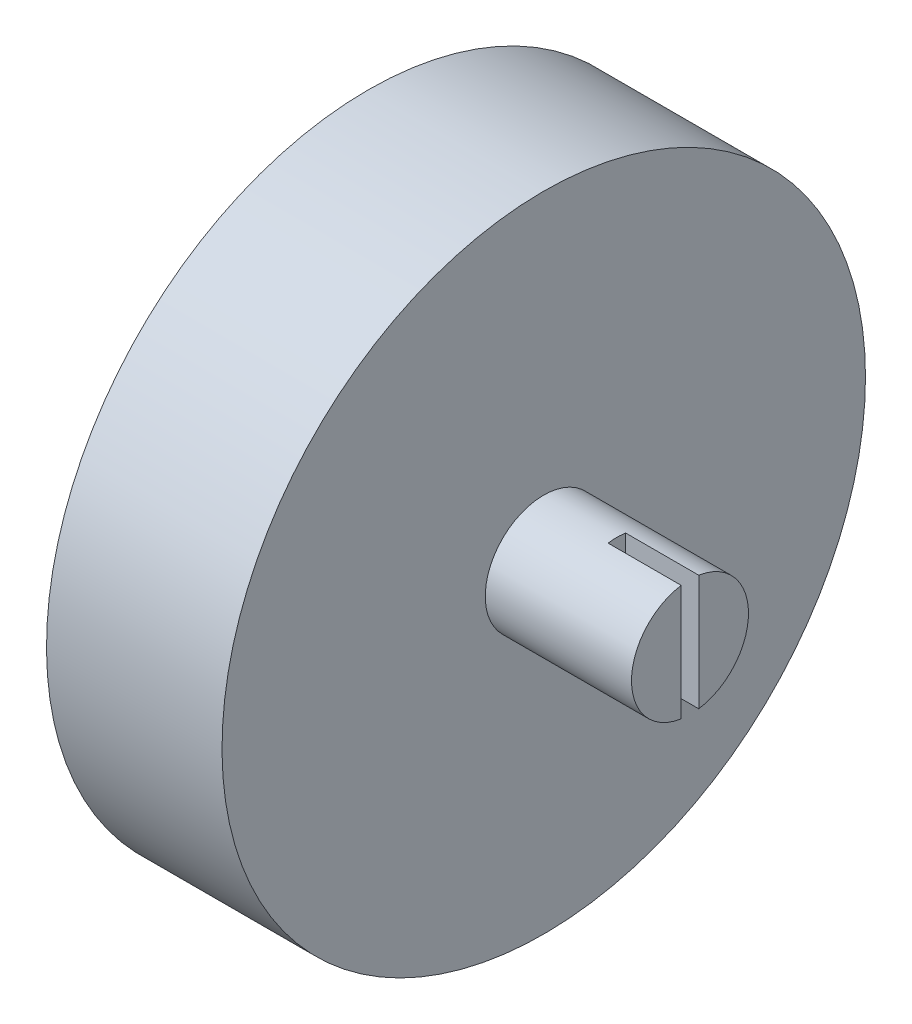
from build123d import *

# Parameters (mm, degrees)
SKETCH1_R           = 22
BOSS_EXTRUDE1_DEPTH = 12
CUT_EXTRUDE2_DEPTH  = 5.5
SKETCH15_W          = 18
SKETCH15_H          = 24.118038922
CUT_EXTRUDE3_DEPTH  = 3
SKETCH16_R          = 4
BOSS_EXTRUDE2_DEPTH = 10
CUT_EXTRUDE4_START  = 22
SKETCH8_W           = 1.2
SKETCH8_H           = 10
CUT_EXTRUDE4_DEPTH  = 5
SKETCH17_W          = 4
SKETCH17_H          = 1.75
BOSS_EXTRUDE3_DEPTH = 1
SKETCH18_W          = 4.25
SKETCH18_H          = 1.737607108
BOSS_EXTRUDE4_DEPTH = 1
SKETCH22_R          = 1.5
CUT_EXTRUDE7_DEPTH  = 7


with BuildPart() as part:
    # Sketch1 → Boss-Extrude1 (new body)
    with BuildSketch(Plane(origin=(0, 0, 0), x_dir=(0, 0, -1), z_dir=(1, 0, 0))):
        Circle(SKETCH1_R)
    extrude(amount=BOSS_EXTRUDE1_DEPTH)

    # Sketch13 → Cut-Extrude2 (cut)
    with BuildSketch(Plane(origin=(0, 0, 0), x_dir=(0, 0, -1), z_dir=(1, 0, 0))):
        with BuildLine():
            Line((-2.670420152, -16.85816067), (-2.670420152, -16.530371213))
            Line((-2.670420152, -16.530371213), (-4.762392892, -10))
            Line((-4.762392892, -10), (-4.762392892, -6.943148259))
            Line((-4.762392892, -6.943148259), (-6.5, -6.943148259))
            Line((-6.5, -6.943148259), (-6.5, 19.556851741))
            Line((-6.5, 19.556851741), (6.5, 19.556851741))
            Line((6.5, 19.556851741), (6.5, -6.943148259))
            Line((6.5, -6.943148259), (4.762392892, -6.943148259))
            Line((4.762392892, -6.943148259), (4.762392892, -10))
            Line((4.762392892, -10), (2.670420152, -16.530371213))
            Line((2.670420152, -16.530371213), (2.670420152, -16.85816067))
            Line((2.670420152, -16.85816067), (2.670420152, -21.837327131))
            ThreePointArc((2.670420152, -21.837327131), (1.836835043, -21.92318492), (1.000584871, -21.977234355))
            Line((1.000584871, -21.977234355), (0, -25.25))
            Line((0, -25.25), (-1.000584871, -21.977234355))
            ThreePointArc((-1.000584871, -21.977234355), (-1.836835043, -21.92318492), (-2.670420152, -21.837327131))
            Line((-2.670420152, -21.837327131), (-2.670420152, -16.85816067))
        make_face()
    extrude(amount=CUT_EXTRUDE2_DEPTH, mode=Mode.SUBTRACT)

    # Sketch15 → Cut-Extrude3 (cut)
    with BuildSketch(Plane.ZY):
        with Locations((0, 5.115871202)):
            Rectangle(SKETCH15_W, SKETCH15_H)
    extrude(amount=-CUT_EXTRUDE3_DEPTH, mode=Mode.SUBTRACT)

    # Sketch16 → Boss-Extrude2 (add)
    with BuildSketch(Plane(origin=(12, 0, 0), x_dir=(0, 0, -1), z_dir=(1, 0, 0))):
        Circle(SKETCH16_R)
    extrude(amount=BOSS_EXTRUDE2_DEPTH)

    # Sketch8 → Cut-Extrude4 (cut)
    with BuildSketch(Plane(origin=(0, 0, 0), x_dir=(0, 0, -1), z_dir=(1, 0, 0)).offset(CUT_EXTRUDE4_START)):
        Rectangle(SKETCH8_W, SKETCH8_H)
    extrude(amount=-CUT_EXTRUDE4_DEPTH, mode=Mode.SUBTRACT)

    # Sketch17 → Boss-Extrude3 (add)
    with BuildSketch(Plane(origin=(0, -6.943148259, 0), x_dir=(1, 0, 0), z_dir=(0, 1, 0))):
        with Locations((2, 5.637392892)):
            Rectangle(SKETCH17_W, SKETCH17_H)
    extrude(amount=BOSS_EXTRUDE3_DEPTH)

    # Sketch18 → Boss-Extrude4 (add)
    with BuildSketch(Plane(origin=(0, -6.943148259, 0), x_dir=(1, 0, 0), z_dir=(0, 1, 0))):
        with Locations((2.125, -5.631196446)):
            Rectangle(SKETCH18_W, SKETCH18_H)
    extrude(amount=BOSS_EXTRUDE4_DEPTH)

    # Sketch22 → Cut-Extrude7 (cut)
    with BuildSketch(Plane(origin=(0, 0, 0), x_dir=(0, 0, -1), z_dir=(1, 0, 0))):
        with Locations((-14, 0)):
            Circle(SKETCH22_R)
        with Locations((14, 0)):
            Circle(SKETCH22_R)
    extrude(amount=CUT_EXTRUDE7_DEPTH, mode=Mode.SUBTRACT)


solid = part.part
